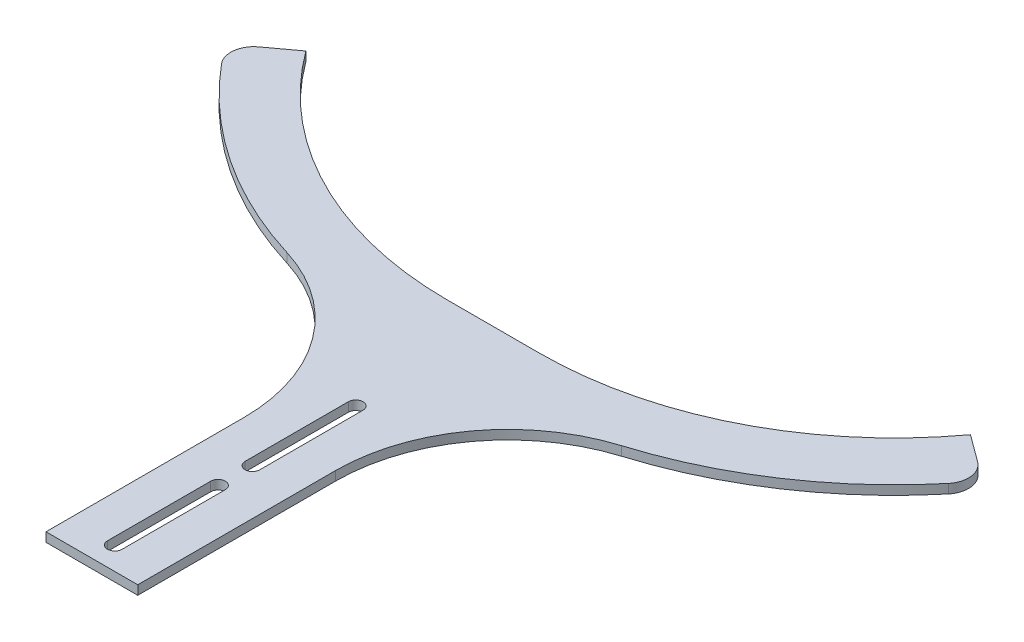
from build123d import *

# Parameters (mm, degrees)
BOSS_EXTRUDE1_DEPTH = 4
FILLET1_R           = 10
CUT_EXTRUDE1_DEPTH  = 10


with BuildPart() as part:
    # Sketch1 → Boss-Extrude1 (new body)
    with BuildSketch(Plane(origin=(0, 0, 0), x_dir=(1, 0, 0), z_dir=(0, 1, 0))):
        with BuildLine():
            Line((-20, 11.278847861), (-20, -75))
            Line((-20, -75), (20, -75))
            Line((20, -75), (20, 11.278847861))
            ThreePointArc((20, 11.278847861), (34.67002501, 55.835487295), (72.941176471, 82.961539667))
            ThreePointArc((72.941176471, 82.961539667), (124.230373948, 108.248410071), (165, 148.346354961))
            Line((165, 148.346354961), (144.861111111, 163.159361217))
            ThreePointArc((144.861111111, 163.159361217), (89.963208148, 116.688216317), (20, 100))
            Line((20, 100), (-20, 100))
            ThreePointArc((-20, 100), (-89.963208148, 116.688216317), (-144.861111111, 163.159361217))
            Line((-144.861111111, 163.159361217), (-165, 148.346354961))
            ThreePointArc((-165, 148.346354961), (-124.230373948, 108.248410071), (-72.941176471, 82.961539667))
            ThreePointArc((-72.941176471, 82.961539667), (-34.67002501, 55.835487295), (-20, 11.278847861))
        make_face()
    extrude(amount=BOSS_EXTRUDE1_DEPTH)

    # Fillet1
    fillet1_edges = [part.edges().sort_by_distance(p)[0] for p in [
        (-165, 2, -148.346354961),
        (165, 2, -148.346354961),
    ]]
    fillet(fillet1_edges, radius=FILLET1_R)

    # Sketch2 → Cut-Extrude1 (cut)
    with BuildSketch(Plane(origin=(0, 4, 0), x_dir=(1, 0, 0), z_dir=(0, 1, 0))):
        with BuildLine():
            Line((3.2, 40), (3.2, -5))
            ThreePointArc((3.2, -5), (0, -8.2), (-3.2, -5))
            Line((-3.2, -5), (-3.2, 40))
            ThreePointArc((-3.2, 40), (0, 43.2), (3.2, 40))
        make_face()
        with BuildLine():
            Line((3.2, -20), (3.2, -65))
            ThreePointArc((3.2, -65), (0, -68.2), (-3.2, -65))
            Line((-3.2, -65), (-3.2, -20))
            ThreePointArc((-3.2, -20), (0, -16.8), (3.2, -20))
        make_face()
    extrude(amount=-CUT_EXTRUDE1_DEPTH, mode=Mode.SUBTRACT)


solid = part.part
